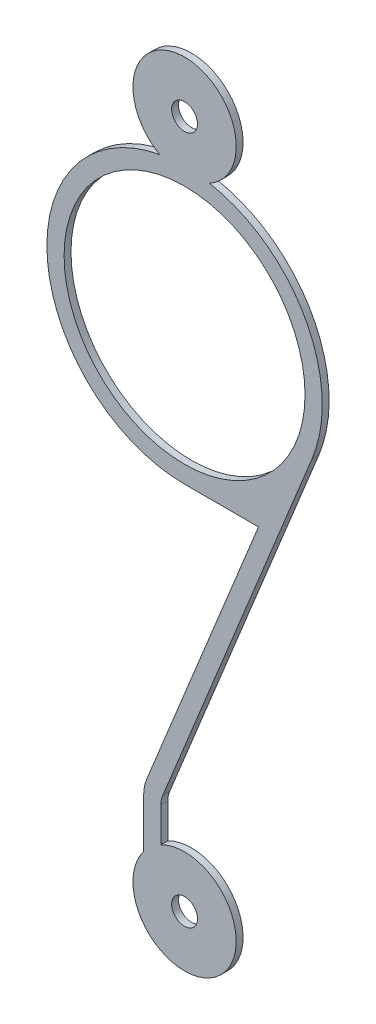
from build123d import *

# Parameters (mm, degrees)
SKETCH1_R           = 0.375
SKETCH1_R_2         = 3.5
BOSS_EXTRUDE1_DEPTH = 0.1


with BuildPart() as part:
    # Sketch1 → Boss-Extrude1 (new body, symmetric)
    with BuildSketch(Plane.XY):
        with BuildLine():
            Line((-0.636628274, -7.407290054), (3.704019046, 3.239952681))
            ThreePointArc((3.704019046, 3.239952681), (3.507926477, 6.672095687), (0.720779018, 8.68452381))
            ThreePointArc((0.720779018, 8.68452381), (0, 11.5), (-0.720779018, 8.68452381))
            ThreePointArc((-0.720779018, 8.68452381), (-3.983597321, 4.388126568), (0, 0.75))
            Line((0, 0.75), (2.148965927, 0.75))
            Line((2.148965927, 0.75), (-1.099630654, -7.218534139))
            ThreePointArc((-1.099630654, -7.218534139), (-1.165325631, -7.4384166), (-1.1875, -7.666829437))
            Line((-1.1875, -7.666829437), (-1.1875, -9.083570106))
            ThreePointArc((-1.1875, -9.083570106), (0.960377242, -11.152248043), (-0.6875, -8.666829437))
            Line((-0.6875, -8.666829437), (-0.6875, -7.666829437))
            ThreePointArc((-0.6875, -7.666829437), (-0.674662207, -7.534590426), (-0.636628274, -7.407290054))
        make_face()
        with Locations((0, -10)):
            Circle(SKETCH1_R, mode=Mode.SUBTRACT)
        with Locations((0, 10)):
            Circle(SKETCH1_R, mode=Mode.SUBTRACT)
        with Locations((0, 4.75)):
            Circle(SKETCH1_R_2, mode=Mode.SUBTRACT)
    extrude(amount=BOSS_EXTRUDE1_DEPTH, both=True)


solid = part.part
